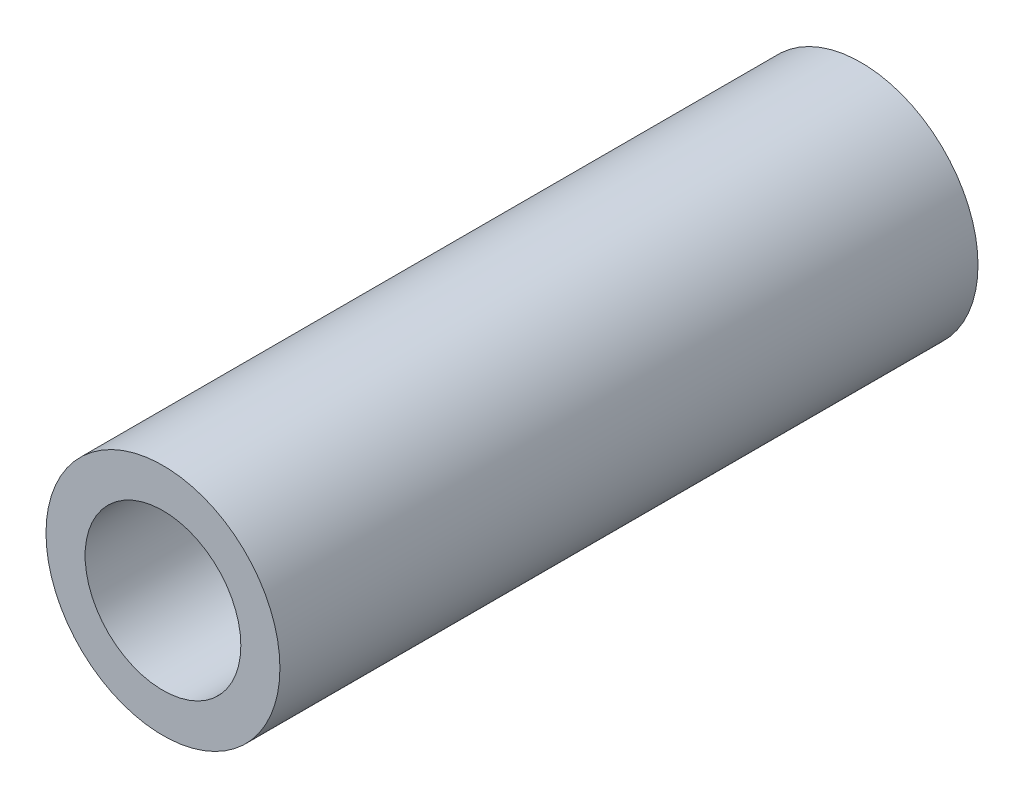
from build123d import *

# Parameters (mm, degrees)
SKETCH5_R           = 4.7879
SKETCH5_R_2         = 3.1877
BOSS_EXTRUDE1_DEPTH = 14.2875


with BuildPart() as part:
    # Sketch5 → Boss-Extrude1 (new, symmetric)
    with BuildSketch(Plane.XY):
        Circle(SKETCH5_R)
        Circle(SKETCH5_R_2, mode=Mode.SUBTRACT)
    extrude(amount=BOSS_EXTRUDE1_DEPTH, both=True)


solid = part.part
